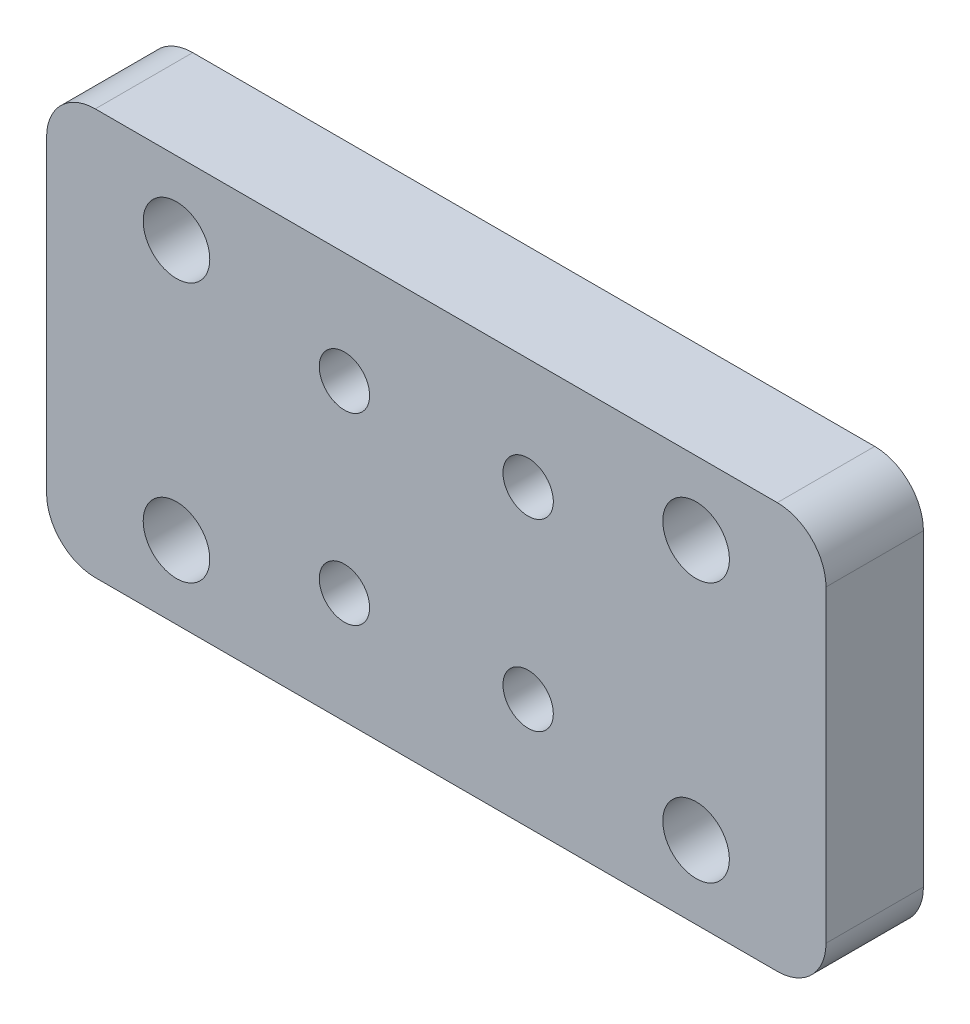
from build123d import *

# Parameters (mm, degrees)
SKETCH1_W           = 48
SKETCH1_H           = 25
SKETCH1_R           = 1.55
SKETCH1_R_2         = 2.05
BOSS_EXTRUDE1_DEPTH = 6
FILLET1_R           = 3
FILLET2_R           = 3
FILLET3_R           = 3
FILLET4_R           = 3


with BuildPart() as part:
    # Sketch1 → Boss-Extrude1 (new body)
    with BuildSketch(Plane.XY):
        with Locations((-2.366412214, -1.965648855)):
            Rectangle(SKETCH1_W, SKETCH1_H)
        with Locations((-8.023266463, 3.691205395)):
            Circle(SKETCH1_R, mode=Mode.SUBTRACT)
        with Locations((-8.023266463, -7.622503104)):
            Circle(SKETCH1_R, mode=Mode.SUBTRACT)
        with Locations((3.290442036, -7.622503104)):
            Circle(SKETCH1_R, mode=Mode.SUBTRACT)
        with Locations((3.290442036, 3.691205395)):
            Circle(SKETCH1_R, mode=Mode.SUBTRACT)
        with Locations((-18.366412214, 6.034351145)):
            Circle(SKETCH1_R_2, mode=Mode.SUBTRACT)
        with Locations((13.633587786, 6.034351145)):
            Circle(SKETCH1_R_2, mode=Mode.SUBTRACT)
        with Locations((13.633587786, -9.965648855)):
            Circle(SKETCH1_R_2, mode=Mode.SUBTRACT)
        with Locations((-18.366412214, -9.965648855)):
            Circle(SKETCH1_R_2, mode=Mode.SUBTRACT)
    extrude(amount=BOSS_EXTRUDE1_DEPTH)

    # Fillet1
    fillet1_edges = [part.edges().sort_by_distance(p)[0] for p in [
        (21.633587786, -14.465648855, 3),
    ]]
    fillet(fillet1_edges, radius=FILLET1_R)

    # Fillet2
    fillet2_edges = [part.edges().sort_by_distance(p)[0] for p in [
        (-26.366412214, -14.465648855, 3),
    ]]
    fillet(fillet2_edges, radius=FILLET2_R)

    # Fillet3
    fillet3_edges = [part.edges().sort_by_distance(p)[0] for p in [
        (21.633587786, 10.534351145, 3),
    ]]
    fillet(fillet3_edges, radius=FILLET3_R)

    # Fillet4
    fillet4_edges = [part.edges().sort_by_distance(p)[0] for p in [
        (-26.366412214, 10.534351145, 3),
    ]]
    fillet(fillet4_edges, radius=FILLET4_R)


solid = part.part
